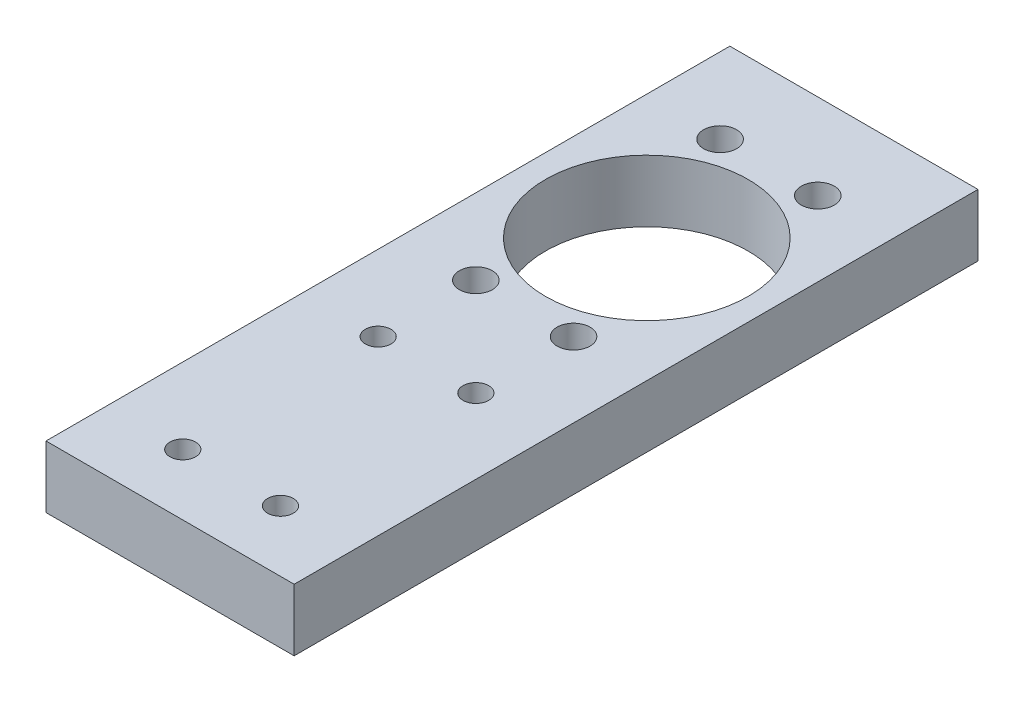
from build123d import *

# Parameters (mm, degrees)
SKETCH2_W           = 101.6
SKETCH2_H           = 280
BOSS_EXTRUDE1_DEPTH = 25.4
SKETCH3_R           = 6.75
SKETCH3_R_2         = 41.5
CUT_EXTRUDE1_DEPTH  = 25.4
SKETCH4_R           = 5.25
CUT_EXTRUDE2_DEPTH  = 25.4


with BuildPart() as part:
    # Sketch2 → Boss-Extrude1 (new body)
    with BuildSketch(Plane(origin=(0, 0, 0), x_dir=(1, 0, 0), z_dir=(0, 1, 0))):
        with Locations((50.8, 140)):
            Rectangle(SKETCH2_W, SKETCH2_H)
    extrude(amount=BOSS_EXTRUDE1_DEPTH)

    # Sketch3 → Cut-Extrude1 (cut)
    with BuildSketch(Plane(origin=(0, 25.4, 0), x_dir=(1, 0, 0), z_dir=(0, 1, 0))):
        with Locations((71, 245)):
            Circle(SKETCH3_R)
        with Locations((31, 245)):
            Circle(SKETCH3_R)
        with Locations((71, 145)):
            Circle(SKETCH3_R)
        with Locations((31, 145)):
            Circle(SKETCH3_R)
        with Locations((51, 195)):
            Circle(SKETCH3_R_2)
    extrude(amount=-CUT_EXTRUDE1_DEPTH, mode=Mode.SUBTRACT)

    # Sketch4 → Cut-Extrude2 (cut)
    with BuildSketch(Plane(origin=(0, 25.4, 0), x_dir=(1, 0, 0), z_dir=(0, 1, 0))):
        with Locations((71, 105)):
            Circle(SKETCH4_R)
        with Locations((31, 105)):
            Circle(SKETCH4_R)
        with Locations((31, 25)):
            Circle(SKETCH4_R)
        with Locations((71, 25)):
            Circle(SKETCH4_R)
    extrude(amount=-CUT_EXTRUDE2_DEPTH, mode=Mode.SUBTRACT)


solid = part.part
